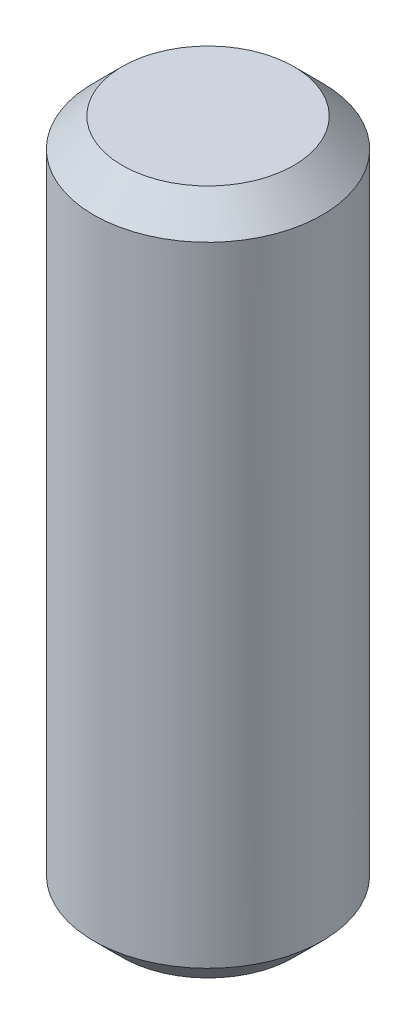
from build123d import *

# Parameters (mm, degrees)
SKETCH_1_W     = 4
SKETCH_1_H     = 24
CHAMFER_1_SIZE = 1


with BuildPart() as part:
    # 草圖1 → 旋轉1 (revolve)
    with BuildSketch(Plane.XY):
        with Locations((2, 12)):
            Rectangle(SKETCH_1_W, SKETCH_1_H)
    revolve(axis=Axis((0, 0, 0), (0, 1, 0)))

    # 導角1
    chamfer_1_edges = [part.edges().sort_by_distance(p)[0] for p in [
        (-4, 0, 0),
        (-4, 24, 0),
    ]]
    chamfer(chamfer_1_edges, length=CHAMFER_1_SIZE)


solid = part.part
